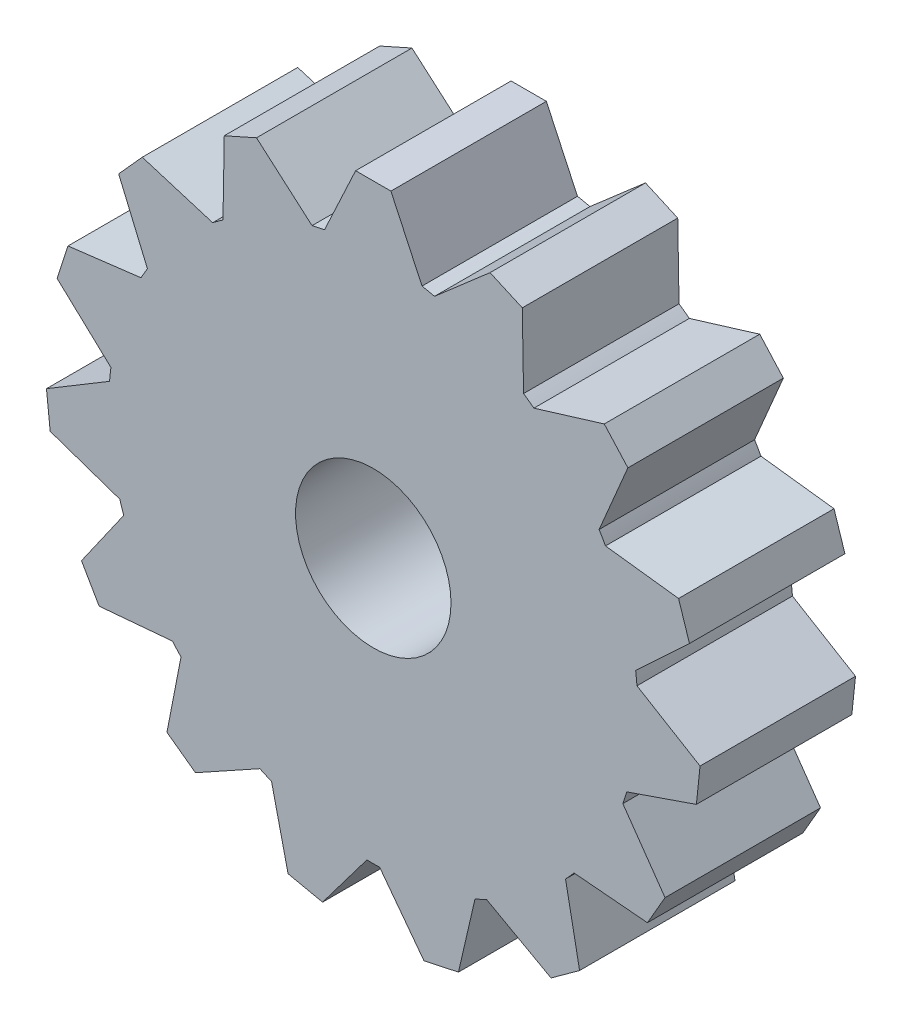
from build123d import *

# Parameters (mm, degrees)
SKETCH1_R           = 2.5
BOSS_EXTRUDE1_DEPTH = 5


with BuildPart() as part:
    # Sketch1 → Boss-Extrude1 (new body)
    with BuildSketch(Plane.XY):
        with BuildLine():
            Line((4.833962587, 7.00231299), (4.831156642, 7.163065475))
            Line((4.831156642, 7.163065475), (4.829008435, 7.286136175))
            Line((4.829008435, 7.286136175), (4.792643442, 9.369485213))
            Line((4.792643442, 9.369485213), (3.755980041, 9.831037496))
            Line((3.755980041, 9.831037496), (2.183417054, 8.464029347))
            Line((2.183417054, 8.464029347), (2.090520269, 8.383275404))
            Line((2.090520269, 8.383275404), (1.969180348, 8.27779622))
            ThreePointArc((1.969180348, 8.27779622), (1.769077823, 8.32285679), (1.567947285, 8.36308094))
            Line((1.567947285, 8.36308094), (1.5, 8.508794362))
            Line((1.5, 8.508794362), (1.447980152, 8.620351287))
            Line((1.447980152, 8.620351287), (0.567384684, 10.508794362))
            Line((0.567384684, 10.508794362), (-0.567384684, 10.508794362))
            Line((-0.567384684, 10.508794362), (-1.447980152, 8.620351287))
            Line((-1.447980152, 8.620351287), (-1.5, 8.508794362))
            Line((-1.5, 8.508794362), (-1.567947285, 8.36308094))
            ThreePointArc((-1.567947285, 8.36308094), (-1.769077823, 8.32285679), (-1.969180348, 8.27779622))
            Line((-1.969180348, 8.27779622), (-2.090520269, 8.383275404))
            Line((-2.090520269, 8.383275404), (-2.183417054, 8.464029347))
            Line((-2.183417054, 8.464029347), (-3.755980041, 9.831037496))
            Line((-3.755980041, 9.831037496), (-4.792643442, 9.369485213))
            Line((-4.792643442, 9.369485213), (-4.829008435, 7.286136175))
            Line((-4.829008435, 7.286136175), (-4.831156642, 7.163065475))
            Line((-4.831156642, 7.163065475), (-4.833962587, 7.00231299))
            ThreePointArc((-4.833962587, 7.00231299), (-5.001343841, 6.883759241), (-5.165818808, 6.761205332))
            Line((-5.165818808, 6.761205332), (-5.319570592, 6.808211969))
            Line((-5.319570592, 6.808211969), (-5.437281616, 6.844199841))
            Line((-5.437281616, 6.844199841), (-7.429901695, 7.453404935))
            Line((-7.429901695, 7.453404935), (-8.18921061, 6.610106952))
            Line((-8.18921061, 6.610106952), (-7.375057289, 4.692081926))
            Line((-7.375057289, 4.692081926), (-7.326962411, 4.578777493))
            Line((-7.326962411, 4.578777493), (-7.264141843, 4.430781509))
            ThreePointArc((-7.264141843, 4.430781509), (-7.368832073, 4.254397181), (-7.469240267, 4.075540618))
            Line((-7.469240267, 4.075540618), (-7.628818832, 4.055946834))
            Line((-7.628818832, 4.055946834), (-7.75099079, 4.040946004))
            Line((-7.75099079, 4.040946004), (-9.819125847, 3.787010949))
            Line((-9.819125847, 3.787010949), (-10.169788866, 2.707781148))
            Line((-10.169788866, 2.707781148), (-8.645891738, 1.286724086))
            Line((-8.645891738, 1.286724086), (-8.555869815, 1.202777285))
            Line((-8.555869815, 1.202777285), (-8.438284981, 1.093127654))
            ThreePointArc((-8.438284981, 1.093127654), (-8.462182296, 0.889411199), (-8.481162228, 0.685177906))
            Line((-8.481162228, 0.685177906), (-8.618974991, 0.602371644))
            Line((-8.618974991, 0.602371644), (-8.724483241, 0.538975892))
            Line((-8.724483241, 0.538975892), (-10.510533936, -0.534191634))
            Line((-10.510533936, -0.534191634), (-10.391918238, -1.662744616))
            Line((-10.391918238, -1.662744616), (-8.42177296, -2.341120038))
            Line((-8.42177296, -2.341120038), (-8.305389601, -2.381194042))
            Line((-8.305389601, -2.381194042), (-8.153371987, -2.433537904))
            ThreePointArc((-8.153371987, -2.433537904), (-8.092344324, -2.62936206), (-8.02661419, -2.82365829))
            Line((-8.02661419, -2.82365829), (-8.118832073, -2.955359075))
            Line((-8.118832073, -2.955359075), (-8.18943328, -3.056188048))
            Line((-8.18943328, -3.056188048), (-9.384575223, -4.763027631))
            Line((-9.384575223, -4.763027631), (-8.817190539, -5.745766731))
            Line((-8.817190539, -5.745766731), (-6.741453128, -5.564163239))
            Line((-6.741453128, -5.564163239), (-6.618832073, -5.553435287))
            Line((-6.618832073, -5.553435287), (-6.458666906, -5.53942265))
            ThreePointArc((-6.458666906, -5.53942265), (-6.323266501, -5.693494731), (-6.18419164, -5.844258315))
            Line((-6.18419164, -5.844258315), (-6.214869332, -6.002081362))
            Line((-6.214869332, -6.002081362), (-6.238355906, -6.12290931))
            Line((-6.238355906, -6.12290931), (-6.635938197, -8.16829288))
            Line((-6.635938197, -8.16829288), (-5.717890494, -8.835293579))
            Line((-5.717890494, -8.835293579), (-3.895474806, -7.825112067))
            Line((-3.895474806, -7.825112067), (-3.787818349, -7.765437119))
            Line((-3.787818349, -7.765437119), (-3.647199641, -7.687490896))
            ThreePointArc((-3.647199641, -7.687490896), (-3.460838455, -7.773170439), (-3.272466173, -7.854332985))
            Line((-3.272466173, -7.854332985), (-3.236299224, -8.010989254))
            Line((-3.236299224, -8.010989254), (-3.208610123, -8.130923927))
            Line((-3.208610123, -8.130923927), (-2.739887171, -10.161186083))
            Line((-2.739887171, -10.161186083), (-1.629915237, -10.397117901))
            Line((-1.629915237, -10.397117901), (-0.3759335, -8.73302793))
            Line((-0.3759335, -8.73302793), (-0.301856422, -8.634724327))
            Line((-0.301856422, -8.634724327), (-0.205098424, -8.506322127))
            ThreePointArc((-0.205098424, -8.506322127), (0, -8.508794362), (0.205098424, -8.506322127))
            Line((0.205098424, -8.506322127), (0.301856422, -8.634724327))
            Line((0.301856422, -8.634724327), (0.3759335, -8.73302793))
            Line((0.3759335, -8.73302793), (1.629915237, -10.397117901))
            Line((1.629915237, -10.397117901), (2.739887171, -10.161186083))
            Line((2.739887171, -10.161186083), (3.208610123, -8.130923927))
            Line((3.208610123, -8.130923927), (3.236299224, -8.010989254))
            Line((3.236299224, -8.010989254), (3.272466173, -7.854332985))
            ThreePointArc((3.272466173, -7.854332985), (3.460838455, -7.773170439), (3.647199641, -7.687490896))
            Line((3.647199641, -7.687490896), (3.787818349, -7.765437119))
            Line((3.787818349, -7.765437119), (3.895474806, -7.825112067))
            Line((3.895474806, -7.825112067), (5.717890494, -8.835293579))
            Line((5.717890494, -8.835293579), (6.635938197, -8.16829288))
            Line((6.635938197, -8.16829288), (6.238355906, -6.12290931))
            Line((6.238355906, -6.12290931), (6.214869332, -6.002081362))
            Line((6.214869332, -6.002081362), (6.18419164, -5.844258315))
            ThreePointArc((6.18419164, -5.844258315), (6.323266501, -5.693494731), (6.458666906, -5.53942265))
            Line((6.458666906, -5.53942265), (6.618832073, -5.553435287))
            Line((6.618832073, -5.553435287), (6.741453128, -5.564163239))
            Line((6.741453128, -5.564163239), (8.817190539, -5.745766731))
            Line((8.817190539, -5.745766731), (9.384575223, -4.763027631))
            Line((9.384575223, -4.763027631), (8.18943328, -3.056188048))
            Line((8.18943328, -3.056188048), (8.118832073, -2.955359075))
            Line((8.118832073, -2.955359075), (8.02661419, -2.82365829))
            ThreePointArc((8.02661419, -2.82365829), (8.092344324, -2.62936206), (8.153371987, -2.433537904))
            Line((8.153371987, -2.433537904), (8.305389601, -2.381194042))
            Line((8.305389601, -2.381194042), (8.42177296, -2.341120038))
            Line((8.42177296, -2.341120038), (10.391918238, -1.662744616))
            Line((10.391918238, -1.662744616), (10.510533936, -0.534191634))
            Line((10.510533936, -0.534191634), (8.724483241, 0.538975892))
            Line((8.724483241, 0.538975892), (8.618974991, 0.602371644))
            Line((8.618974991, 0.602371644), (8.481162228, 0.685177906))
            ThreePointArc((8.481162228, 0.685177906), (8.462182296, 0.889411199), (8.438284981, 1.093127654))
            Line((8.438284981, 1.093127654), (8.555869815, 1.202777285))
            Line((8.555869815, 1.202777285), (8.645891738, 1.286724086))
            Line((8.645891738, 1.286724086), (10.169788866, 2.707781148))
            Line((10.169788866, 2.707781148), (9.819125847, 3.787010949))
            Line((9.819125847, 3.787010949), (7.75099079, 4.040946004))
            Line((7.75099079, 4.040946004), (7.628818832, 4.055946834))
            Line((7.628818832, 4.055946834), (7.469240267, 4.075540618))
            ThreePointArc((7.469240267, 4.075540618), (7.368832073, 4.254397181), (7.264141843, 4.430781509))
            Line((7.264141843, 4.430781509), (7.326962411, 4.578777493))
            Line((7.326962411, 4.578777493), (7.375057289, 4.692081926))
            Line((7.375057289, 4.692081926), (8.18921061, 6.610106952))
            Line((8.18921061, 6.610106952), (7.429901695, 7.453404935))
            Line((7.429901695, 7.453404935), (5.437281616, 6.844199841))
            Line((5.437281616, 6.844199841), (5.319570592, 6.808211969))
            Line((5.319570592, 6.808211969), (5.165818808, 6.761205332))
            ThreePointArc((5.165818808, 6.761205332), (5.001343841, 6.883759241), (4.833962587, 7.00231299))
        make_face()
        Circle(SKETCH1_R, mode=Mode.SUBTRACT)
    extrude(amount=BOSS_EXTRUDE1_DEPTH)


solid = part.part
